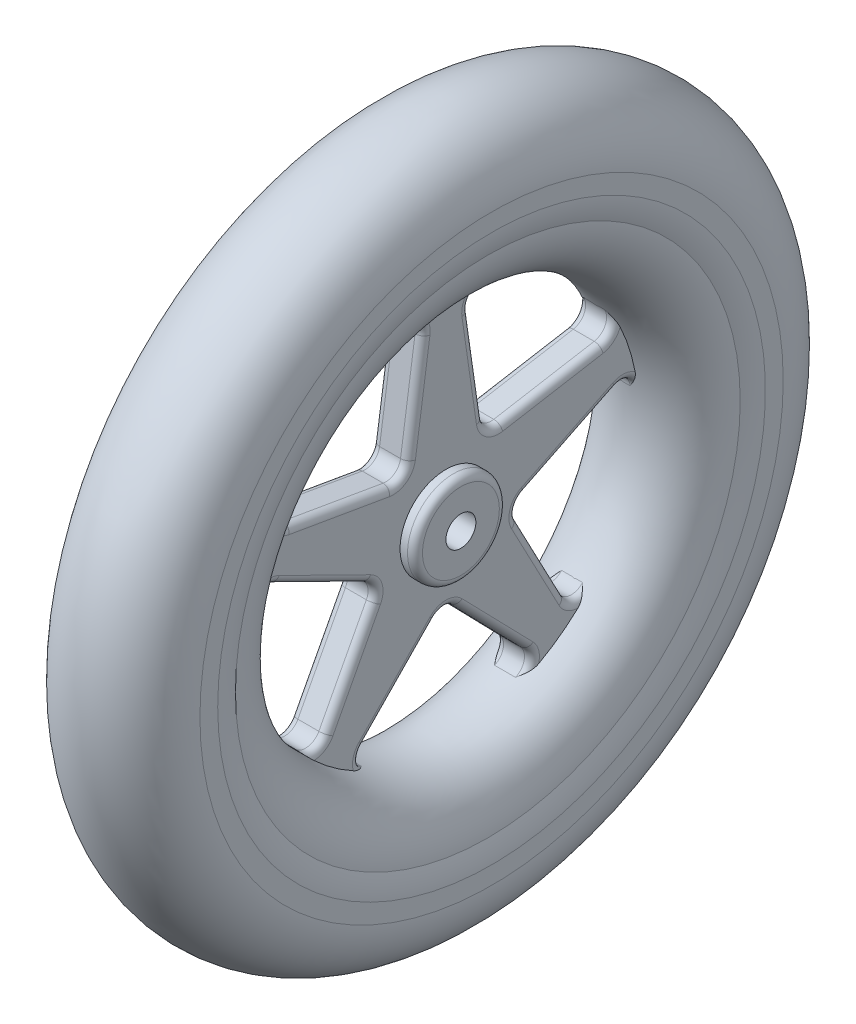
from build123d import *

# Parameters (mm, degrees)
BOSS_EXTRUDE1_DEPTH      = 1.2
BOSS_EXTRUDE1_DEPTH_BACK = 1.2
SKETCH2_R                = 1
BOSS_EXTRUDE2_DEPTH      = 2.2
BOSS_EXTRUDE2_DEPTH_BACK = 2.2
SKETCH2_3_R              = 3.07
SKETCH2_3_R_2            = 1
FILLET1_R                = 0.5


with BuildPart() as part:
    # Sketch1 → Revolve1 (revolve)
    with BuildSketch(Plane.XY):
        with BuildLine():
            Line((4, 16.875), (-4, 16.875))
            ThreePointArc((-4, 16.875), (0, 12.875), (4, 16.875))
        make_face()
    revolve(axis=Axis((-7.041792719, 0, 0), (1, 0, 0)))

    # Sketch3 → Revolve2 (revolve)
    with BuildSketch(Plane.XY):
        with BuildLine():
            ThreePointArc((4, 16.875), (4.187033556, 17.582271675), (4.25, 18.311140662))
            Line((4.25, 18.311140662), (4.25, 19.5))
            ThreePointArc((4.25, 19.5), (0, 23.75), (-4.25, 19.5))
            Line((-4.25, 19.5), (-4.25, 18.311140662))
            ThreePointArc((-4.25, 18.311140662), (-4.187033556, 17.582271675), (-4, 16.875))
            Line((-4, 16.875), (4, 16.875))
        make_face()
    revolve(axis=Axis((-7.041792719, 0, 0), (1, 0, 0)))


with BuildPart() as body_2:
    # Sketch2 → Boss-Extrude1 (new, two sides: drawn at the far end of the back side and taken through both)
    with BuildSketch(Plane(origin=(0, 0, 0), x_dir=(0, 0, -1), z_dir=(1, 0, 0)).offset(-BOSS_EXTRUDE1_DEPTH_BACK)):
        with BuildLine():
            ThreePointArc((-0.716845331, -5.302767778), (-0.389080826, -5.078796379), (0, -5))
            ThreePointArc((0, -5), (0.389080826, -5.078796379), (0.716845331, -5.302767778))
            Line((0.716845331, -5.302767778), (5.466845331, -10.186385054))
            ThreePointArc((5.466845331, -10.186385054), (5.731265004, -11.076280173), (5.149999991, -11.800132418))
            ThreePointArc((5.149999991, -11.800132418), (7.567735071, -10.416093841), (9.631155225, -8.544382601))
            ThreePointArc((9.631155225, -8.544382601), (8.763110085, -8.873515729), (7.99847977, -8.347044969))
            Line((7.99847977, -8.347044969), (4.82171446, -2.320405784))
            ThreePointArc((4.82171446, -2.320405784), (4.755282581, -1.545084972), (5.26474924, -0.956884937))
            Line((5.26474924, -0.956884937), (11.377175996, 2.051512783))
            ThreePointArc((11.377175996, 2.051512783), (12.305226641, 2.027998165), (12.81403033, 1.251499778))
            ThreePointArc((12.81403033, 1.251499778), (12.244852649, 3.978593798), (11.102381421, 6.519413453))
            ThreePointArc((11.102381421, 6.519413453), (11.147164883, 5.592145762), (10.410177687, 5.027627557))
            Line((10.410177687, 5.027627557), (3.696828752, 3.868678136))
            ThreePointArc((3.696828752, 3.868678136), (2.938926261, 4.045084972), (2.536948641, 4.711380364))
            Line((2.536948641, 4.711380364), (1.56463613, 11.454289682))
            ThreePointArc((1.56463613, 11.454289682), (1.873783284, 12.329651881), (2.769506124, 12.573601745))
            ThreePointArc((2.769506124, 12.573601745), (1.2e-08, 12.875), (-2.769506101, 12.57360175))
            ThreePointArc((-2.769506101, 12.57360175), (-1.873783275, 12.329651873), (-1.56463613, 11.454289682))
            Line((-1.56463613, 11.454289682), (-2.536948641, 4.711380364))
            ThreePointArc((-2.536948641, 4.711380364), (-2.938926261, 4.045084972), (-3.696828752, 3.868678136))
            Line((-3.696828752, 3.868678136), (-10.410177687, 5.027627557))
            ThreePointArc((-10.410177687, 5.027627557), (-11.147164948, 5.5921459), (-11.102381267, 6.519413717))
            ThreePointArc((-11.102381267, 6.519413717), (-12.244852648, 3.9785938), (-12.81403036, 1.251499478))
            ThreePointArc((-12.81403036, 1.251499478), (-12.305226773, 2.027998091), (-11.377175996, 2.051512783))
            Line((-11.377175996, 2.051512783), (-5.26474924, -0.956884937))
            ThreePointArc((-5.26474924, -0.956884937), (-4.755282581, -1.545084972), (-4.82171446, -2.320405784))
            Line((-4.82171446, -2.320405784), (-7.99847977, -8.347044969))
            ThreePointArc((-7.99847977, -8.347044969), (-8.763110146, -8.873515736), (-9.631155307, -8.544382509))
            ThreePointArc((-9.631155307, -8.544382509), (-7.567735127, -10.4160938), (-5.150000007, -11.800132411))
            ThreePointArc((-5.150000007, -11.800132411), (-5.731265006, -11.076280165), (-5.466845331, -10.186385054))
            Line((-5.466845331, -10.186385054), (-0.716845331, -5.302767778))
        make_face()
        Circle(SKETCH2_R, mode=Mode.SUBTRACT)
    extrude(amount=BOSS_EXTRUDE1_DEPTH + BOSS_EXTRUDE1_DEPTH_BACK)

    # Sketch2_3 → Boss-Extrude2 (add, two sides: drawn at the far end of the back side and taken through both)
    with BuildSketch(Plane(origin=(0, 0, 0), x_dir=(0, 0, -1), z_dir=(1, 0, 0)).offset(-BOSS_EXTRUDE2_DEPTH_BACK)):
        Circle(SKETCH2_3_R)
        Circle(SKETCH2_3_R_2, mode=Mode.SUBTRACT)
    extrude(amount=BOSS_EXTRUDE2_DEPTH + BOSS_EXTRUDE2_DEPTH_BACK)

    # Fillet1
    fillet1_edges = [body_2.edges().sort_by_distance(p)[0] for p in [
        (-1.2, 5.5921459, 11.147164948),
        (-1.2, 4.448152847, 7.05350322),
        (-1.2, 12.329651873, 1.873783275),
        (-1.2, 8.082835023, 2.050792386),
        (1.2, 5.5921459, 11.147164948),
        (1.2, 4.448152847, 7.05350322),
        (1.2, 12.329651873, 1.873783275),
        (1.2, 8.082835023, 2.050792386),
        (-1.2, 12.329651881, -1.873783284),
        (-1.2, 8.082835023, -2.050792386),
        (-1.2, 5.592145762, -11.147164883),
        (-1.2, 4.448152847, -7.05350322),
        (1.2, 12.329651881, -1.873783284),
        (1.2, 8.082835023, -2.050792386),
        (1.2, 5.592145762, -11.147164883),
        (1.2, 4.448152847, -7.05350322),
        (-1.2, 2.027998165, -12.305226641),
        (-1.2, 0.547313923, -8.320962618),
        (-1.2, -8.873515729, -8.763110085),
        (-1.2, -5.333725376, -6.410097115),
        (1.2, 2.027998165, -12.305226641),
        (1.2, 0.547313923, -8.320962618),
        (1.2, -8.873515729, -8.763110085),
        (1.2, -5.333725376, -6.410097115),
        (-1.2, -11.076280173, -5.731265004),
        (-1.2, -7.744576416, -3.091845331),
        (-1.2, -5, 0),
        (-1.2, -7.744576416, 3.091845331),
        (1.2, -11.076280173, -5.731265004),
        (1.2, -7.744576416, -3.091845331),
        (1.2, -5, 0),
        (1.2, -7.744576416, 3.091845331),
        (-1.2, 4.045084972, 2.938926261),
        (1.2, 4.045084972, 2.938926261),
        (-1.2, 4.045084972, -2.938926261),
        (1.2, 4.045084972, -2.938926261),
        (-1.2, -1.545084972, -4.755282581),
        (1.2, -1.545084972, -4.755282581),
        (-1.2, -11.076280165, 5.731265006),
        (1.2, -11.076280165, 5.731265006),
        (-1.2, 2.027998091, 12.305226773),
        (1.2, 2.027998091, 12.305226773),
        (-1.2, 0.547313923, 8.320962618),
        (1.2, 0.547313923, 8.320962618),
        (-1.2, -1.545084972, 4.755282581),
        (1.2, -1.545084972, 4.755282581),
        (-1.2, -5.333725376, 6.410097115),
        (1.2, -5.333725376, 6.410097115),
        (-1.2, -8.873515736, 8.763110146),
        (1.2, -8.873515736, 8.763110146),
        (-2.2, 0, 3.07),
        (2.2, 0, 3.07),
    ]]
    fillet(fillet1_edges, radius=FILLET1_R)


solid = Compound([part.part, body_2.part])
